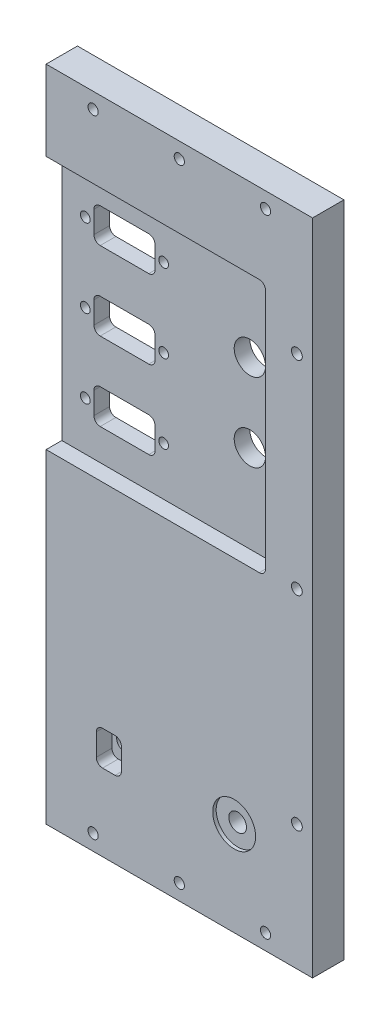
from build123d import *

# Parameters (mm, degrees)
SKETCH1_W                                           = 85
SKETCH1_H                                           = 210
BOSS_EXTRUDE1_DEPTH                                 = 10
RS232_BNC_FEEDTHROUGHS_REACH                        = 12
SKETCH2_R                                           = 5
LED_THRU_HOLE_REACH                                 = 12
SKETCH2_3_R                                         = 2.5
F_1_4_40_THREADED_THROUGH_HOLE_REACH                = 12
SKETCH3_R                                           = 2.82956
SKETCH3_3_R                                         = 6.85
SKETCH3_3_R_2                                       = 2.82956
SWITCH_RECESS_DEPTH                                 = 1.1
CBORE_FOR_4_BINDING_HEAD_MACHINE_SCREW1_D           = 3.4544
CBORE_FOR_4_BINDING_HEAD_MACHINE_SCREW1_CBORE_D     = 6.74624
CBORE_FOR_4_BINDING_HEAD_MACHINE_SCREW1_CBORE_DEPTH = 1.7272
RS232_FEEDTHRUS_REACH                               = 12
SKETCH2_7_W                                         = 9.75
SKETCH2_7_H                                         = 11
SKETCH2_7_R                                         = 1.55
SKETCH2_8_W                                         = 8
SKETCH2_8_H                                         = 11
SKETCH2_8_R                                         = 2.5
SKETCH2_8_W_2                                       = 70
SKETCH2_8_H_2                                       = 81
SKETCH2_8_R_2                                       = 1.55
SKETCH2_8_W_3                                       = 19.5
SKETCH2_8_R_3                                       = 5
CUT_EXTRUDE6_DEPTH                                  = 5
FILLET4_R                                           = 2
CBORE_FOR_4_BINDING_HEAD_MACHINE_SCREW2_D           = 3.2639
CBORE_FOR_4_BINDING_HEAD_MACHINE_SCREW2_DEPTH       = 10
CBORE_FOR_4_BINDING_HEAD_MACHINE_SCREW2_CBORE_D     = 6.74624
CBORE_FOR_4_BINDING_HEAD_MACHINE_SCREW2_CBORE_DEPTH = 1.7272
F_4_40_TAPPED_HOLE1_D                               = 2.2606
F_4_40_TAPPED_HOLE1_DEPTH                           = 7.6
F_4_40_TAPPED_HOLE1_TIP                             = 0.679152758


with BuildPart() as part:
    # Sketch1 → Boss-Extrude1 (new body)
    with BuildSketch(Plane.XY):
        with Locations((-115.863171355, -13.158567775)):
            Rectangle(SKETCH1_W, SKETCH1_H)
    extrude(amount=BOSS_EXTRUDE1_DEPTH)

    # Sketch2 → RS232 _ BNC feedthroughs (cut, up to next)
    with BuildSketch(Plane.XY.offset(10), mode=Mode.PRIVATE) as rs232_bnc_feedthroughs_sk1:
        with Locations((-98.363171355, 38.341432225)):
            Circle(SKETCH2_R)
    rs232_bnc_feedthroughs_tool1 = extrude(rs232_bnc_feedthroughs_sk1.sketch, amount=-RS232_BNC_FEEDTHROUGHS_REACH, mode=Mode.PRIVATE) & part.part
    add(rs232_bnc_feedthroughs_tool1.solids().sort_by_distance((-98.363171, 38.341432, 10))[0], mode=Mode.SUBTRACT)
    # Sketch2 → RS232 _ BNC feedthroughs (cut, up to next)
    with BuildSketch(Plane.XY.offset(10), mode=Mode.PRIVATE) as rs232_bnc_feedthroughs_sk2:
        with Locations((-98.363171355, 13.341432225)):
            Circle(SKETCH2_R)
    rs232_bnc_feedthroughs_tool2 = extrude(rs232_bnc_feedthroughs_sk2.sketch, amount=-RS232_BNC_FEEDTHROUGHS_REACH, mode=Mode.PRIVATE) & part.part
    add(rs232_bnc_feedthroughs_tool2.solids().sort_by_distance((-98.363171, 13.341432, 10))[0], mode=Mode.SUBTRACT)

    # Sketch2_3 → LED thru hole (cut, up to next)
    with BuildSketch(Plane.XY.offset(10), mode=Mode.PRIVATE) as led_thru_hole_sk1:
        with Locations((-138.363171355, -88.158567775)):
            Circle(SKETCH2_3_R)
    led_thru_hole_tool1 = extrude(led_thru_hole_sk1.sketch, amount=-LED_THRU_HOLE_REACH, mode=Mode.PRIVATE) & part.part
    add(led_thru_hole_tool1.solids().sort_by_distance((-138.363171, -88.158568, 10))[0], mode=Mode.SUBTRACT)

    # Sketch3 → 1_4-40 threaded through hole (cut, up to next)
    with BuildSketch(Plane.XY.offset(10), mode=Mode.PRIVATE) as f_1_4_40_threaded_through_hole_sk1:
        with Locations((-98.363171355, -88.158567775)):
            Circle(SKETCH3_R)
    f_1_4_40_threaded_through_hole_tool1 = extrude(f_1_4_40_threaded_through_hole_sk1.sketch, amount=-F_1_4_40_THREADED_THROUGH_HOLE_REACH, mode=Mode.PRIVATE) & part.part
    add(f_1_4_40_threaded_through_hole_tool1.solids().sort_by_distance((-98.363171, -88.158568, 10))[0], mode=Mode.SUBTRACT)

    # Sketch3_3 → switch recess (cut)
    with BuildSketch(Plane.XY.offset(10)):
        with Locations((-98.363171355, -88.158567775)):
            Circle(SKETCH3_3_R)
        with Locations((-98.363171355, -88.158567775)):
            Circle(SKETCH3_3_R_2, mode=Mode.SUBTRACT)
    extrude(amount=-SWITCH_RECESS_DEPTH, mode=Mode.SUBTRACT)

    # CBORE for _4 Binding Head Machine Screw1 (through all)
    with Locations(Plane(origin=(0, 0, 0), x_dir=(-1, 0, 0), z_dir=(0, 0, -1))):
        with Locations((78.363171355, 51.841432225), (78.363171355, -13.158567775), (78.363171355, -78.158567775)):
            CounterBoreHole(CBORE_FOR_4_BINDING_HEAD_MACHINE_SCREW1_D / 2, CBORE_FOR_4_BINDING_HEAD_MACHINE_SCREW1_CBORE_D / 2, CBORE_FOR_4_BINDING_HEAD_MACHINE_SCREW1_CBORE_DEPTH)

    # Sketch2_7 → RS232 feedthrus (cut, up to next)
    with BuildSketch(Plane.XY.offset(10), mode=Mode.PRIVATE) as rs232_feedthrus_sk1:
        with Locations((-143.238171355, 50.841432225)):
            Rectangle(SKETCH2_7_W, SKETCH2_7_H)
    rs232_feedthrus_tool1 = extrude(rs232_feedthrus_sk1.sketch, amount=-RS232_FEEDTHRUS_REACH, mode=Mode.PRIVATE) & part.part
    add(rs232_feedthrus_tool1.solids().sort_by_distance((-143.238171, 50.841432, 10))[0], mode=Mode.SUBTRACT)
    # Sketch2_7 → RS232 feedthrus (cut, up to next)
    with BuildSketch(Plane.XY.offset(10), mode=Mode.PRIVATE) as rs232_feedthrus_sk2:
        with Locations((-133.488171355, 50.841432225)):
            Rectangle(SKETCH2_7_W, SKETCH2_7_H)
    rs232_feedthrus_tool2 = extrude(rs232_feedthrus_sk2.sketch, amount=-RS232_FEEDTHRUS_REACH, mode=Mode.PRIVATE) & part.part
    add(rs232_feedthrus_tool2.solids().sort_by_distance((-133.488171, 50.841432, 10))[0], mode=Mode.SUBTRACT)
    # Sketch2_7 → RS232 feedthrus (cut, up to next)
    with BuildSketch(Plane.XY.offset(10), mode=Mode.PRIVATE) as rs232_feedthrus_sk3:
        with Locations((-143.238171355, 25.841432225)):
            Rectangle(SKETCH2_7_W, SKETCH2_7_H)
    rs232_feedthrus_tool3 = extrude(rs232_feedthrus_sk3.sketch, amount=-RS232_FEEDTHRUS_REACH, mode=Mode.PRIVATE) & part.part
    add(rs232_feedthrus_tool3.solids().sort_by_distance((-143.238171, 25.841432, 10))[0], mode=Mode.SUBTRACT)
    # Sketch2_7 → RS232 feedthrus (cut, up to next)
    with BuildSketch(Plane.XY.offset(10), mode=Mode.PRIVATE) as rs232_feedthrus_sk4:
        with Locations((-133.488171355, 25.841432225)):
            Rectangle(SKETCH2_7_W, SKETCH2_7_H)
    rs232_feedthrus_tool4 = extrude(rs232_feedthrus_sk4.sketch, amount=-RS232_FEEDTHRUS_REACH, mode=Mode.PRIVATE) & part.part
    add(rs232_feedthrus_tool4.solids().sort_by_distance((-133.488171, 25.841432, 10))[0], mode=Mode.SUBTRACT)
    # Sketch2_7 → RS232 feedthrus (cut, up to next)
    with BuildSketch(Plane.XY.offset(10), mode=Mode.PRIVATE) as rs232_feedthrus_sk5:
        with Locations((-133.488171355, 0.841432225)):
            Rectangle(SKETCH2_7_W, SKETCH2_7_H)
    rs232_feedthrus_tool5 = extrude(rs232_feedthrus_sk5.sketch, amount=-RS232_FEEDTHRUS_REACH, mode=Mode.PRIVATE) & part.part
    add(rs232_feedthrus_tool5.solids().sort_by_distance((-133.488171, 0.841432, 10))[0], mode=Mode.SUBTRACT)
    # Sketch2_7 → RS232 feedthrus (cut, up to next)
    with BuildSketch(Plane.XY.offset(10), mode=Mode.PRIVATE) as rs232_feedthrus_sk6:
        with Locations((-143.238171355, 0.841432225)):
            Rectangle(SKETCH2_7_W, SKETCH2_7_H)
    rs232_feedthrus_tool6 = extrude(rs232_feedthrus_sk6.sketch, amount=-RS232_FEEDTHRUS_REACH, mode=Mode.PRIVATE) & part.part
    add(rs232_feedthrus_tool6.solids().sort_by_distance((-143.238171, 0.841432, 10))[0], mode=Mode.SUBTRACT)
    # Sketch2_7 → RS232 feedthrus (cut, up to next)
    with BuildSketch(Plane.XY.offset(10), mode=Mode.PRIVATE) as rs232_feedthrus_sk7:
        with Locations((-125.863171355, 50.841432225)):
            Circle(SKETCH2_7_R)
    rs232_feedthrus_tool7 = extrude(rs232_feedthrus_sk7.sketch, amount=-RS232_FEEDTHRUS_REACH, mode=Mode.PRIVATE) & part.part
    add(rs232_feedthrus_tool7.solids().sort_by_distance((-125.863171, 50.841432, 10))[0], mode=Mode.SUBTRACT)
    # Sketch2_7 → RS232 feedthrus (cut, up to next)
    with BuildSketch(Plane.XY.offset(10), mode=Mode.PRIVATE) as rs232_feedthrus_sk8:
        with Locations((-150.863171355, 50.841432225)):
            Circle(SKETCH2_7_R)
    rs232_feedthrus_tool8 = extrude(rs232_feedthrus_sk8.sketch, amount=-RS232_FEEDTHRUS_REACH, mode=Mode.PRIVATE) & part.part
    add(rs232_feedthrus_tool8.solids().sort_by_distance((-150.863171, 50.841432, 10))[0], mode=Mode.SUBTRACT)
    # Sketch2_7 → RS232 feedthrus (cut, up to next)
    with BuildSketch(Plane.XY.offset(10), mode=Mode.PRIVATE) as rs232_feedthrus_sk9:
        with Locations((-150.863171355, 25.841432225)):
            Circle(SKETCH2_7_R)
    rs232_feedthrus_tool9 = extrude(rs232_feedthrus_sk9.sketch, amount=-RS232_FEEDTHRUS_REACH, mode=Mode.PRIVATE) & part.part
    add(rs232_feedthrus_tool9.solids().sort_by_distance((-150.863171, 25.841432, 10))[0], mode=Mode.SUBTRACT)
    # Sketch2_7 → RS232 feedthrus (cut, up to next)
    with BuildSketch(Plane.XY.offset(10), mode=Mode.PRIVATE) as rs232_feedthrus_sk10:
        with Locations((-125.863171355, 25.841432225)):
            Circle(SKETCH2_7_R)
    rs232_feedthrus_tool10 = extrude(rs232_feedthrus_sk10.sketch, amount=-RS232_FEEDTHRUS_REACH, mode=Mode.PRIVATE) & part.part
    add(rs232_feedthrus_tool10.solids().sort_by_distance((-125.863171, 25.841432, 10))[0], mode=Mode.SUBTRACT)
    # Sketch2_7 → RS232 feedthrus (cut, up to next)
    with BuildSketch(Plane.XY.offset(10), mode=Mode.PRIVATE) as rs232_feedthrus_sk11:
        with Locations((-150.863171355, 0.841432225)):
            Circle(SKETCH2_7_R)
    rs232_feedthrus_tool11 = extrude(rs232_feedthrus_sk11.sketch, amount=-RS232_FEEDTHRUS_REACH, mode=Mode.PRIVATE) & part.part
    add(rs232_feedthrus_tool11.solids().sort_by_distance((-150.863171, 0.841432, 10))[0], mode=Mode.SUBTRACT)
    # Sketch2_7 → RS232 feedthrus (cut, up to next)
    with BuildSketch(Plane.XY.offset(10), mode=Mode.PRIVATE) as rs232_feedthrus_sk12:
        with Locations((-125.863171355, 0.841432225)):
            Circle(SKETCH2_7_R)
    rs232_feedthrus_tool12 = extrude(rs232_feedthrus_sk12.sketch, amount=-RS232_FEEDTHRUS_REACH, mode=Mode.PRIVATE) & part.part
    add(rs232_feedthrus_tool12.solids().sort_by_distance((-125.863171, 0.841432, 10))[0], mode=Mode.SUBTRACT)

    # Sketch2_8 → Cut-Extrude6 (cut)
    with BuildSketch(Plane.XY.offset(10)):
        with Locations((-138.363171355, -88.158567775)):
            Rectangle(SKETCH2_8_W, SKETCH2_8_H)
        with Locations((-138.363171355, -88.158567775)):
            Circle(SKETCH2_8_R, mode=Mode.SUBTRACT)
        with Locations((-123.363171355, 25.841432225)):
            Rectangle(SKETCH2_8_W_2, SKETCH2_8_H_2)
        with Locations((-150.863171355, 0.841432225)):
            Circle(SKETCH2_8_R_2, mode=Mode.SUBTRACT)
        with Locations((-150.863171355, 25.841432225)):
            Circle(SKETCH2_8_R_2, mode=Mode.SUBTRACT)
        with Locations((-138.363171355, 0.841432225)):
            Rectangle(SKETCH2_8_W_3, SKETCH2_8_H, mode=Mode.SUBTRACT)
        with Locations((-125.863171355, 0.841432225)):
            Circle(SKETCH2_8_R_2, mode=Mode.SUBTRACT)
        with Locations((-138.363171355, 25.841432225)):
            Rectangle(SKETCH2_8_W_3, SKETCH2_8_H, mode=Mode.SUBTRACT)
        with Locations((-125.863171355, 25.841432225)):
            Circle(SKETCH2_8_R_2, mode=Mode.SUBTRACT)
        with Locations((-150.863171355, 50.841432225)):
            Circle(SKETCH2_8_R_2, mode=Mode.SUBTRACT)
        with Locations((-138.363171355, 50.841432225)):
            Rectangle(SKETCH2_8_W_3, SKETCH2_8_H, mode=Mode.SUBTRACT)
        with Locations((-125.863171355, 50.841432225)):
            Circle(SKETCH2_8_R_2, mode=Mode.SUBTRACT)
        with Locations((-98.363171355, 13.341432225)):
            Circle(SKETCH2_8_R_3, mode=Mode.SUBTRACT)
        with Locations((-98.363171355, 38.341432225)):
            Circle(SKETCH2_8_R_3, mode=Mode.SUBTRACT)
    extrude(amount=-CUT_EXTRUDE6_DEPTH, mode=Mode.SUBTRACT)

    # Fillet4
    fillet4_edges = [part.edges().sort_by_distance(p)[0] for p in [
        (-128.613171355, 56.341432225, 2.5),
        (-128.613171355, 45.341432225, 2.5),
        (-88.363171355, 66.341432225, 7.5),
        (-88.363171355, -14.658567775, 7.5),
        (-134.363171355, -93.658567775, 7.5),
        (-142.363171355, -93.658567775, 7.5),
        (-142.363171355, -82.658567775, 7.5),
        (-134.363171355, -82.658567775, 7.5),
        (-148.113171355, 20.341432225, 2.5),
        (-148.113171355, 31.341432225, 2.5),
        (-128.613171355, 31.341432225, 2.5),
        (-128.613171355, 20.341432225, 2.5),
        (-128.613171355, 6.341432225, 2.5),
        (-128.613171355, -4.658567775, 2.5),
        (-148.113171355, -4.658567775, 2.5),
        (-148.113171355, 6.341432225, 2.5),
        (-148.113171355, 45.341432225, 2.5),
        (-148.113171355, 56.341432225, 2.5),
    ]]
    fillet(fillet4_edges, radius=FILLET4_R)

    # CBORE for _4 Binding Head Machine Screw2
    with Locations(Plane(origin=(0, 0, 0), x_dir=(-1, 0, 0), z_dir=(0, 0, -1))):
        with Locations((143.363171355, 86.841432225), (115.863171355, 86.841432225), (88.363171355, 86.841432225), (88.363171355, -113.158567775), (115.863171355, -113.158567775), (143.363171355, -113.158567775)):
            CounterBoreHole(CBORE_FOR_4_BINDING_HEAD_MACHINE_SCREW2_D / 2, CBORE_FOR_4_BINDING_HEAD_MACHINE_SCREW2_CBORE_D / 2, CBORE_FOR_4_BINDING_HEAD_MACHINE_SCREW2_CBORE_DEPTH, depth=CBORE_FOR_4_BINDING_HEAD_MACHINE_SCREW2_DEPTH)

    # 4-40 Tapped Hole1
    with Locations(Plane.ZY.offset(158.363171355)):
        with Locations((5, -63.158567775)):
            Hole(F_4_40_TAPPED_HOLE1_D / 2, depth=F_4_40_TAPPED_HOLE1_DEPTH)
            with Locations((0, 0, -(F_4_40_TAPPED_HOLE1_DEPTH + F_4_40_TAPPED_HOLE1_TIP / 2))):  # 118° drill point
                Cone(0, F_4_40_TAPPED_HOLE1_D / 2, F_4_40_TAPPED_HOLE1_TIP, mode=Mode.SUBTRACT)


solid = part.part
